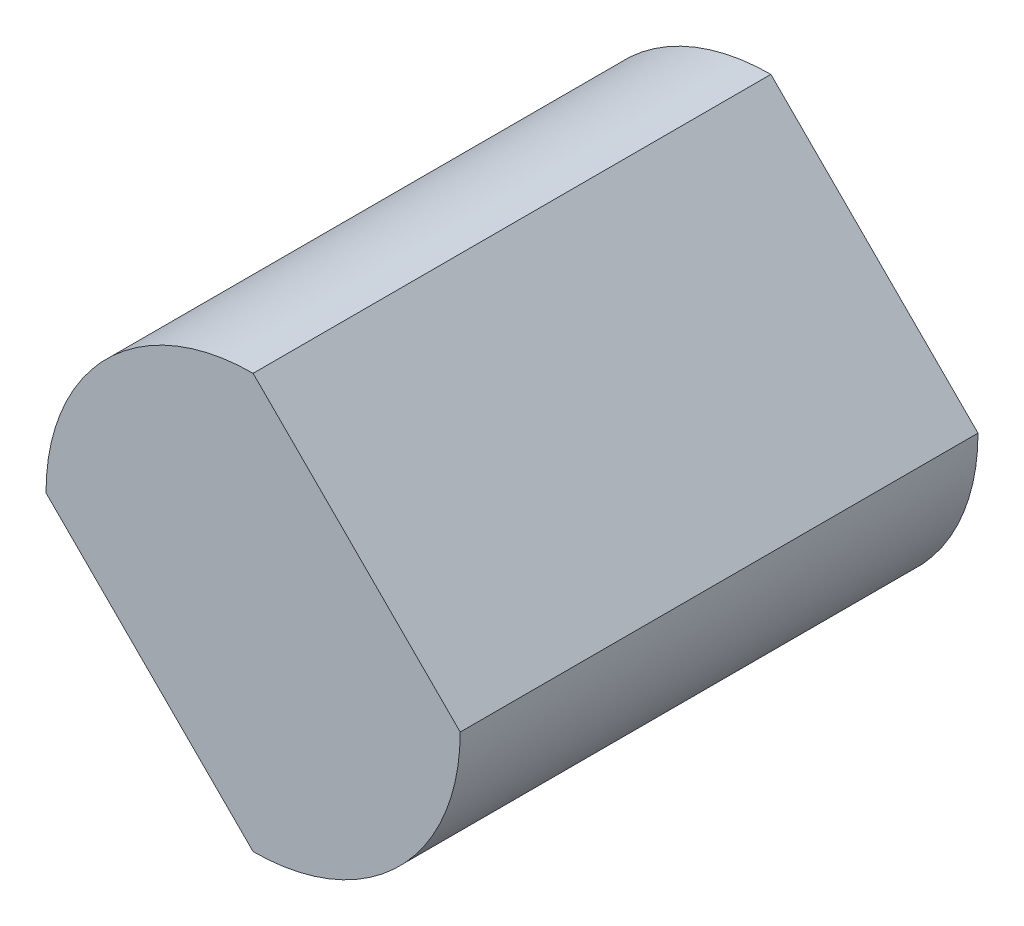
from build123d import *

# Parameters (mm, degrees)
BOSS_EXTRUDE1_DEPTH = 25


with BuildPart() as part:
    # Sketch1 → Boss-Extrude1 (new body)
    with BuildSketch(Plane.XY):
        with BuildLine():
            Line((-20, 0), (-10, -10))
            ThreePointArc((-10, -10), (-2.928932188, -7.071067812), (0, 0))
            Line((0, 0), (-10, 10))
            ThreePointArc((-10, 10), (-17.071067812, 7.071067812), (-20, 0))
        make_face()
    extrude(amount=BOSS_EXTRUDE1_DEPTH)


solid = part.part
